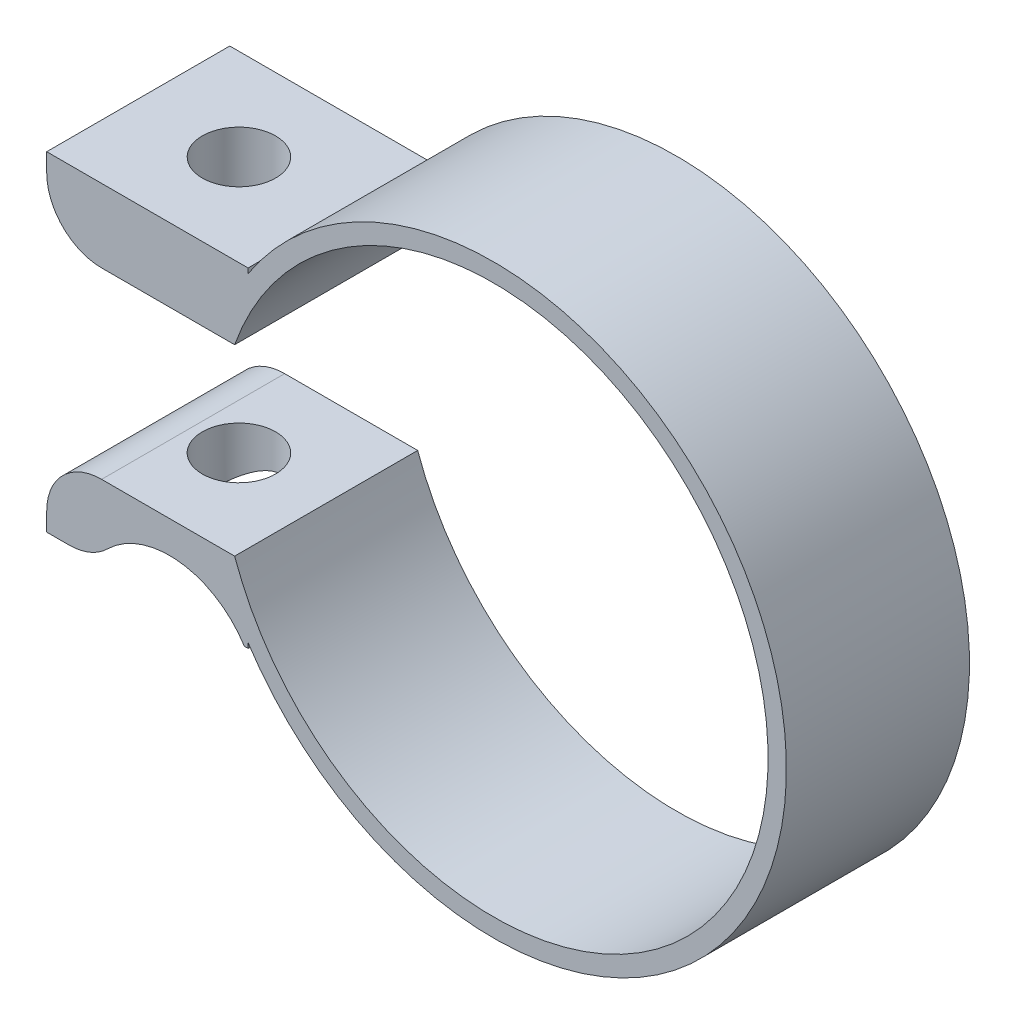
from build123d import *

# Parameters (mm, degrees)
SALIENTE_EXTRUIR4_DEPTH = 10
REDONDEO4_R             = 3
CROQUIS4_R              = 2
CORTAR_EXTRUIR1_DEPTH   = 21
CROQUIS5_R              = 4.836264875
CORTAR_EXTRUIR2_DEPTH   = 21
REDONDEO5_R             = 3


with BuildPart() as part:
    # Croquis1 → Saliente-Extruir4 (new body)
    with BuildSketch(Plane.XY):
        with BuildLine():
            ThreePointArc((-15.198684154, 5), (-14.424283954, 6.923874089), (-13.407545238, 8.731422032))
            Line((-13.407545238, 8.731422032), (-13.407545238, 9))
            Line((-13.407545238, 9), (-24.407545238, 9))
            Line((-24.407545238, 9), (-24.407545238, 5))
            Line((-24.407545238, 5), (-15.198684154, 5))
        make_face()
        with BuildLine():
            Line((15, 0), (16, 0))
            ThreePointArc((16, 0), (4.554079281, 15.338199435), (-13.407545238, 8.731422032))
            ThreePointArc((-13.407545238, 8.731422032), (-14.424283954, 6.923874089), (-15.198684154, 5))
            Line((-15.198684154, 5), (-14.142135624, 5))
            ThreePointArc((-14.142135624, 5), (2.536529681, 14.783978395), (15, 0))
        make_face()
        with BuildLine():
            Line((-13.407545238, -9), (-13.407545238, -8.731422032))
            ThreePointArc((-13.407545238, -8.731422032), (-14.424283954, -6.923874089), (-15.198684154, -5))
            Line((-15.198684154, -5), (-24.407545238, -5))
            Line((-24.407545238, -5), (-24.407545238, -9))
            Line((-24.407545238, -9), (-13.407545238, -9))
        make_face()
        with BuildLine():
            ThreePointArc((-13.407545238, -8.731422032), (4.554079281, -15.338199435), (16, 0))
            Line((16, 0), (15, 0))
            ThreePointArc((15, 0), (2.536529681, -14.783978395), (-14.142135624, -5))
            Line((-14.142135624, -5), (-15.198684154, -5))
            ThreePointArc((-15.198684154, -5), (-14.424283954, -6.923874089), (-13.407545238, -8.731422032))
        make_face()
    extrude(amount=SALIENTE_EXTRUIR4_DEPTH)

    # Redondeo4
    redondeo4_edges = [part.edges().sort_by_distance(p)[0] for p in [
        (-24.407545238, 5, 5),
        (-24.407545238, -5, 5),
    ]]
    fillet(redondeo4_edges, radius=REDONDEO4_R)

    # Croquis4 → Cortar-Extruir1 (cut)
    with BuildSketch(Plane(origin=(0, 9, 0), x_dir=(1, 0, 0), z_dir=(0, 1, 0))):
        with Locations((-18.907545238, -5)):
            Circle(CROQUIS4_R)
    extrude(amount=-CORTAR_EXTRUIR1_DEPTH, mode=Mode.SUBTRACT)

    # Croquis5 → Cortar-Extruir2 (cut)
    with BuildSketch(Plane(origin=(0, 0, 0), x_dir=(-1, 0, 0), z_dir=(0, 0, -1))):
        with Locations((17.698992991, -11.582378958)):
            Circle(CROQUIS5_R)
    extrude(amount=-CORTAR_EXTRUIR2_DEPTH, mode=Mode.SUBTRACT)

    # Redondeo5
    redondeo5_edges = [part.edges().sort_by_distance(p)[0] for p in [
        (-21.788097643, -9, 5),
    ]]
    fillet(redondeo5_edges, radius=REDONDEO5_R)


solid = part.part
